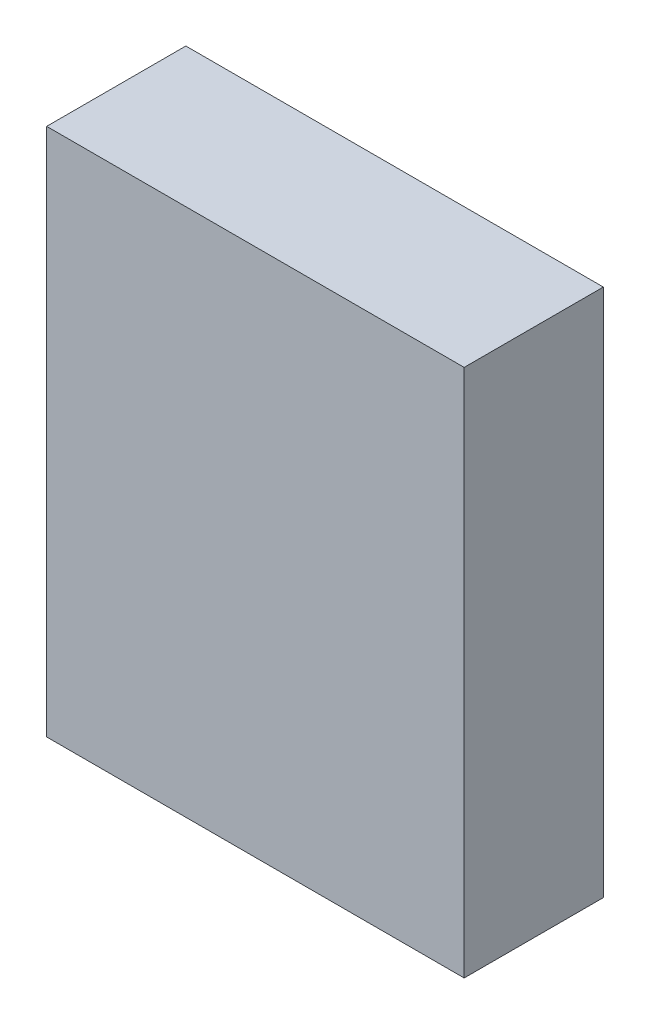
from build123d import *

# Parameters (mm, degrees)
SKIZZE1_W                       = 15
SKIZZE1_H                       = 19
AUFSATZ_LINEAR_AUSTRAGEN1_DEPTH = 5


with BuildPart() as part:
    # Skizze1 → Aufsatz-Linear austragen1 (new body)
    with BuildSketch(Plane.XY):
        Rectangle(SKIZZE1_W, SKIZZE1_H)
    extrude(amount=AUFSATZ_LINEAR_AUSTRAGEN1_DEPTH)


solid = part.part
